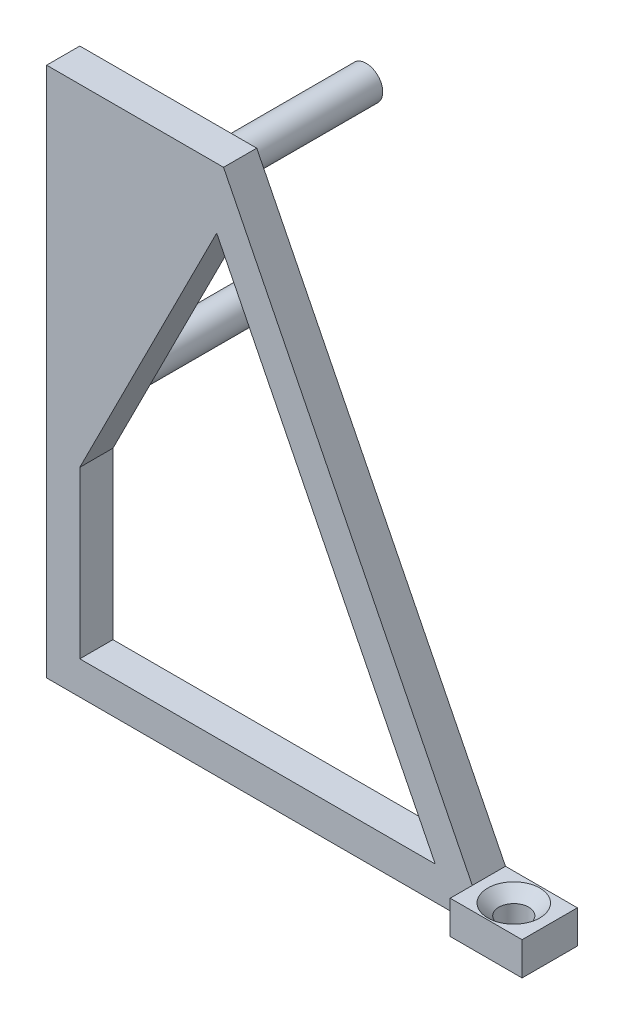
from build123d import *

# Parameters (mm, degrees)
SKICA1_R                     = 1.5
P_IDAT_VYSUNUT_M1_DEPTH      = 3
SKICA2_R                     = 1.5
P_IDAT_VYSUNUT_M2_DEPTH      = 13
P_IDAT_VYSUNUT_M2_DEPTH_BACK = 3
SKICA3_W                     = 6.5
SKICA3_H                     = 3
P_IDAT_VYSUNUT_M3_DEPTH      = 2
SKICA4_R                     = 1.35
ODEBRAT_VYSUNUT_M1_DEPTH     = 3
ZKOSEN_1_SIZE                = 1


with BuildPart() as part:
    # Skica1 → Přidat vysunutím1 (new body)
    with BuildSketch(Plane.XY):
        Polygon((0, 0), (0, 48), (16, 48), (38.5, 3), (45, 3), (45, 0), (40, 0), align=None)
        with Locations((12.9, 45.1)):
            Circle(SKICA1_R, mode=Mode.SUBTRACT)
        with Locations((2.5, 22.9)):
            Circle(SKICA1_R, mode=Mode.SUBTRACT)
        Polygon((3, 3), (35.145898034, 3), (15.37827124, 42.535253588), (3, 18), align=None, mode=Mode.SUBTRACT)
    extrude(amount=P_IDAT_VYSUNUT_M1_DEPTH)

    # Skica2 → Přidat vysunutím2 (add, two sides)
    with BuildSketch(Plane(origin=(0, 0, 0), x_dir=(-1, 0, 0), z_dir=(0, 0, -1))) as p_idat_vysunut_m2_sk:
        with Locations((-12.9, 45.1)):
            Circle(SKICA2_R)
        with Locations((-2.5, 22.9)):
            Circle(SKICA2_R)
    extrude(amount=P_IDAT_VYSUNUT_M2_DEPTH)
    extrude(p_idat_vysunut_m2_sk.sketch, amount=-P_IDAT_VYSUNUT_M2_DEPTH_BACK)

    # Skica3 → Přidat vysunutím3 (add)
    with BuildSketch(Plane.XY.offset(3)):
        with Locations((41.75, 1.5)):
            Rectangle(SKICA3_W, SKICA3_H)
    extrude(amount=P_IDAT_VYSUNUT_M3_DEPTH)

    # Skica4 → Odebrat vysunutím1 (cut)
    with BuildSketch(Plane(origin=(0, 3, 0), x_dir=(1, 0, 0), z_dir=(0, 1, 0))):
        with Locations((41.75, -2.5)):
            Circle(SKICA4_R)
    extrude(amount=-ODEBRAT_VYSUNUT_M1_DEPTH, mode=Mode.SUBTRACT)

    # Zkosení1
    zkosen_1_edges = [part.edges().sort_by_distance(p)[0] for p in [
        (40.4, 3, 2.5),
    ]]
    chamfer(zkosen_1_edges, length=ZKOSEN_1_SIZE)


solid = part.part
